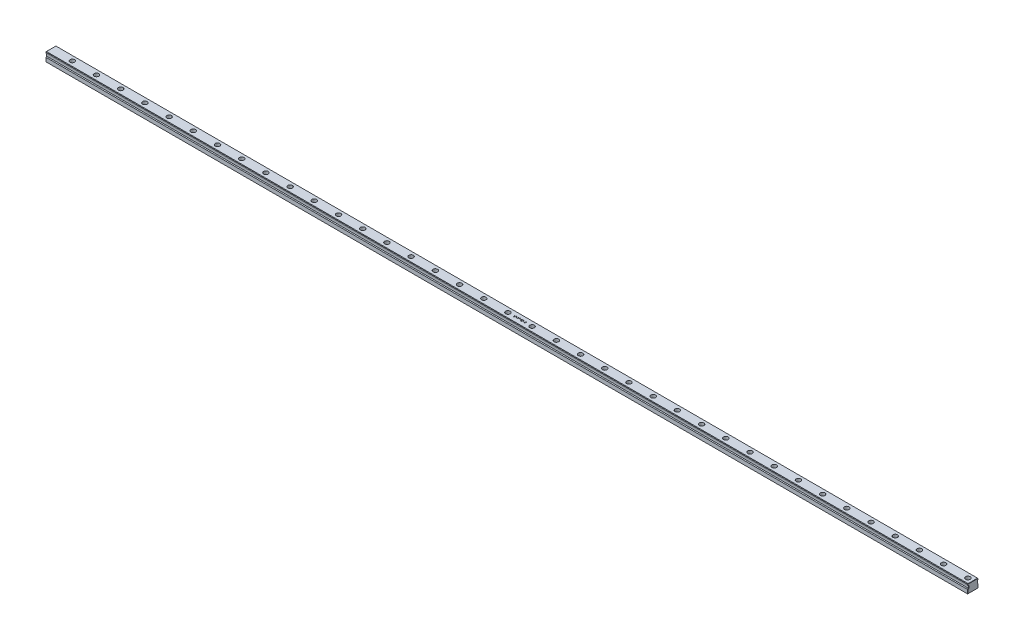
from build123d import *

# Parameters (mm, degrees)
BOSS_EXTRUDE1_DEPTH = 4000
SKETCH2_R           = 10
CUT_EXTRUDE1_DEPTH  = 17
SKETCH3_R           = 7
CUT_EXTRUDE2_DEPTH  = 22
LPATTERN1_COUNT     = 38
LPATTERN1_PITCH     = 105
CHAMFER1_SIZE       = 1
CUT_EXTRUDE3_DEPTH  = 2


with BuildPart() as part:
    # Sketch1 → Boss-Extrude1 (new body)
    with BuildSketch(Plane(origin=(0, 0, 0), x_dir=(0, 0, -1), z_dir=(1, 0, 0))):
        Polygon((-22.5, 0), (22.5, 0), (22.5, 17), (19.5, 20), (19.5, 29), (22.5, 32), (22.5, 36), (20.5, 38), (-20.5, 38), (-22.5, 36), (-22.5, 32), (-19.5, 29), (-19.5, 20), (-22.5, 17), align=None)
    extrude(amount=BOSS_EXTRUDE1_DEPTH)

    # Sketch2 → Cut-Extrude1 (cut)
    with BuildSketch(Plane(origin=(0, 38, 0), x_dir=(1, 0, 0), z_dir=(0, 1, 0))):
        with Locations(Location((3977.5, 0, 0), (0, 0, 270))):  # turned: the seam where the file's is
            Circle(SKETCH2_R)
    cut_extrude1 = extrude(amount=-CUT_EXTRUDE1_DEPTH, mode=Mode.SUBTRACT)

    # Sketch3 → Cut-Extrude2 (cut, through all)
    with BuildSketch(Plane(origin=(0, 21, 0), x_dir=(1, 0, 0), z_dir=(0, 1, 0))):
        with Locations(Location((3977.5, 0, 0), (0, 0, 270))):  # turned: the seam where the file's is
            Circle(SKETCH3_R)
    cut_extrude2 = extrude(amount=-CUT_EXTRUDE2_DEPTH, mode=Mode.SUBTRACT)

    # LPattern1: Cut-Extrude1, Cut-Extrude2 ×38
    with Locations(*[(-i * LPATTERN1_PITCH, 0, 0) for i in range(1, LPATTERN1_COUNT)]):
        add(cut_extrude1, mode=Mode.SUBTRACT)
        add(cut_extrude2, mode=Mode.SUBTRACT)

    # Chamfer1
    chamfer1_edges = [part.edges().sort_by_distance(p)[0] for p in [
        (4000, 8.5, -22.5),
        (0, 18.5, 21),
        (0, 24.5, 19.5),
        (4000, 18.5, -21),
        (0, 30.5, 21),
        (0, 34, 22.5),
        (0, 37, 21.5),
        (0, 38, 0),
        (0, 37, -21.5),
        (0, 34, -22.5),
        (0, 30.5, -21),
        (4000, 24.5, -19.5),
        (0, 24.5, -19.5),
        (0, 18.5, -21),
        (0, 8.5, -22.5),
        (0, 0, 0),
        (0, 8.5, 22.5),
        (4000, 30.5, -21),
        (4000, 34, -22.5),
        (4000, 37, -21.5),
        (4000, 38, 0),
        (4000, 37, 21.5),
        (4000, 34, 22.5),
        (4000, 30.5, 21),
        (4000, 8.5, 22.5),
        (4000, 24.5, 19.5),
        (4000, 18.5, 21),
        (4000, 0, 0),
    ]]
    chamfer(chamfer1_edges, length=CHAMFER1_SIZE)

    # Sketch5 → Cut-Extrude3 (cut)
    with BuildSketch(Plane(origin=(0, 38, 0), x_dir=(1, 0, 0), z_dir=(0, 1, 0))):
        with BuildLine():
            Line((2007.80688282, -1.573210853), (2008.589714518, -1.103882844))
            add(Edge.make_bspline(
                [(2008.589714518, -1.103882844), (2008.662523187, -1.22576153), (2008.802021788, -1.459276387), (2009.034726426, -1.774813286), (2009.27584892, -2.043000659), (2009.527174865, -2.262278349), (2009.787170186, -2.434916029), (2010.057532161, -2.557159434), (2010.337349702, -2.633401702), (2010.527780438, -2.642662348), (2010.622850869, -2.647285622)],
                knots=[0, 0, 0, 0, 1.272034388, 2.437168799, 3.508375237, 4.49857839, 5.41946034, 6.295179144, 7.148887113, 8, 8, 8, 8], degree=3))
            add(Edge.make_bspline(
                [(2010.622850869, -2.647285622), (2010.704043188, -2.645024301), (2010.86500715, -2.640541227), (2011.101973917, -2.597464938), (2011.332113269, -2.531287014), (2011.550681957, -2.436510799), (2011.754664103, -2.321844389), (2011.933540151, -2.183345128), (2012.088178826, -2.028282875), (2012.214673775, -1.855291268), (2012.311723035, -1.669243812), (2012.386314549, -1.478278274), (2012.427708807, -1.279394771), (2012.433944383, -1.145487921), (2012.437091154, -1.077912125)],
                knots=[0, 0, 0, 0, 1.095163259, 2.171163733, 3.241058638, 4.321873601, 5.38011039, 6.391990106, 7.366004449, 8.327778327, 9.272591725, 10.192022065, 11.087607919, 12, 12, 12, 12], degree=3))
            add(Edge.make_bspline(
                [(2012.437091154, -1.077912125), (2012.433190373, -1.000810293), (2012.425260657, -0.844073536), (2012.358237782, -0.612828621), (2012.252803317, -0.383983696), (2012.155535489, -0.242428265), (2012.10503695, -0.168936931)],
                knots=[0, 0, 0, 0, 0.938893495, 1.908633276, 2.914225137, 4, 4, 4, 4], degree=3))
            add(Edge.make_bspline(
                [(2012.10503695, -0.168936931), (2012.063575117, -0.115896377), (2011.976531184, -0.004544368), (2011.826889432, 0.161204484), (2011.651295754, 0.332174051), (2011.455759265, 0.514892806), (2011.233157135, 0.700862601), (2010.990461419, 0.898951587), (2010.721475792, 1.101626592), (2010.532829208, 1.237549839), (2010.435490676, 1.307683996)],
                knots=[0, 0, 0, 0, 0.722233717, 1.516239348, 2.393582979, 3.351407094, 4.387010283, 5.505090956, 6.712668013, 8, 8, 8, 8], degree=3))
            add(Edge.make_bspline(
                [(2010.435490676, 1.307683996), (2010.33806052, 1.377080467), (2010.151781479, 1.509761236), (2009.89127648, 1.706675488), (2009.658325505, 1.886708226), (2009.453963941, 2.051554258), (2009.278281674, 2.201235941), (2009.129894316, 2.334315905), (2009.012581883, 2.454393243), (2008.947347326, 2.532290127), (2008.918058618, 2.567263907)],
                knots=[0, 0, 0, 0, 1.452282411, 2.77665338, 3.964542531, 5.026858415, 5.96415736, 6.766646006, 7.446254459, 8, 8, 8, 8], degree=3))
            add(Edge.make_bspline(
                [(2008.918058618, 2.567263907), (2008.877120842, 2.621770817), (2008.796611212, 2.728965971), (2008.690338656, 2.89651299), (2008.600012121, 3.068024547), (2008.52920345, 3.243961522), (2008.469576371, 3.421853938), (2008.429471013, 3.604022859), (2008.404358359, 3.78965087), (2008.401786644, 3.914569924), (2008.400499273, 3.977102983)],
                knots=[0, 0, 0, 0, 1.068054152, 2.10047183, 3.106115577, 4.101338837, 5.06977816, 6.043150881, 7.020423561, 8, 8, 8, 8], degree=3))
            add(Edge.make_bspline(
                [(2008.400499273, 3.977102983), (2008.403952639, 4.075077595), (2008.410785556, 4.26893268), (2008.468571925, 4.552118419), (2008.559781456, 4.822486648), (2008.68756168, 5.077360656), (2008.85228426, 5.31010398), (2009.0429059, 5.523393831), (2009.269948791, 5.702698205), (2009.51906094, 5.859363443), (2009.791730924, 5.981987037), (2010.077456856, 6.074487963), (2010.376692859, 6.126899958), (2010.579371986, 6.13442144), (2010.682212514, 6.138237882)],
                knots=[0, 0, 0, 0, 1.005424448, 1.989358655, 2.955360095, 3.929531133, 4.905563448, 5.876582895, 6.856512386, 7.866279853, 8.892233794, 9.918561126, 10.94386622, 12, 12, 12, 12], degree=3))
            add(Edge.make_bspline(
                [(2010.682212514, 6.138237882), (2010.79133753, 6.134474048), (2011.008352356, 6.126988982), (2011.327570072, 6.061908014), (2011.634911968, 5.95422082), (2011.882147273, 5.832013329), (2012.075644371, 5.709957292), (2012.223209726, 5.59877984), (2012.372745481, 5.470787365), (2012.525457835, 5.325638943), (2012.678759163, 5.162002747), (2012.83492538, 4.980999466), (2012.994321675, 4.783735246), (2013.096863221, 4.642912087), (2013.149430897, 4.570719436)],
                knots=[0, 0, 0, 0, 1.286793592, 2.559021753, 3.825965368, 5.121522368, 5.803751409, 6.523245864, 7.299691795, 8.125521123, 9.008227632, 9.944561021, 10.946284179, 12, 12, 12, 12], degree=3))
            Line((2013.149430897, 4.570719436), (2012.398135074, 4.001218651))
            add(Edge.make_bspline(
                [(2012.398135074, 4.001218651), (2012.352769794, 4.059661645), (2012.265406872, 4.172209186), (2012.132772605, 4.329824958), (2012.007760557, 4.473801894), (2011.884595958, 4.598857545), (2011.769783641, 4.711840273), (2011.658348967, 4.808571296), (2011.551895579, 4.889998392), (2011.417707087, 4.976896978), (2011.249120624, 5.06303606), (2011.037494871, 5.135926329), (2010.816339519, 5.179728264), (2010.665713202, 5.185519696), (2010.589459944, 5.188451557)],
                knots=[0, 0, 0, 0, 1.181633172, 2.275549214, 3.290209073, 4.226197932, 5.078386478, 5.862611352, 6.581680152, 7.217281963, 8.414376989, 9.595101626, 10.782541182, 12, 12, 12, 12], degree=3))
            add(Edge.make_bspline(
                [(2010.589459944, 5.188451557), (2010.493795811, 5.185245601), (2010.309316544, 5.179063217), (2010.047404878, 5.111541589), (2009.811677201, 5.005227084), (2009.609131873, 4.856227037), (2009.440494454, 4.679694411), (2009.318507095, 4.476550357), (2009.245084784, 4.25223025), (2009.236125253, 4.095751284), (2009.231562307, 4.016059063)],
                knots=[0, 0, 0, 0, 1.14458467, 2.207223713, 3.21896685, 4.227309161, 5.202851033, 6.127160689, 7.046193047, 8, 8, 8, 8], degree=3))
            add(Edge.make_bspline(
                [(2009.231562307, 4.016059063), (2009.232602455, 3.966445776), (2009.234684451, 3.867138074), (2009.263721936, 3.720422854), (2009.301026411, 3.574078268), (2009.360141291, 3.428762268), (2009.441752823, 3.281933443), (2009.548922768, 3.131063429), (2009.683895489, 2.97482245), (2009.787286751, 2.87320294), (2009.841874223, 2.8195509)],
                knots=[0, 0, 0, 0, 0.858281714, 1.717966888, 2.583508476, 3.4729293, 4.427298488, 5.488583878, 6.674047936, 8, 8, 8, 8], degree=3))
            add(Edge.make_bspline(
                [(2009.841874223, 2.8195509), (2009.862144938, 2.801461269), (2009.910303515, 2.758484447), (2009.998346069, 2.688125704), (2010.114611389, 2.601335036), (2010.256063463, 2.493947761), (2010.425310441, 2.369378059), (2010.622370933, 2.22921871), (2010.845048322, 2.068919683), (2011.003062558, 1.956848691), (2011.086613723, 1.897590346)],
                knots=[0, 0, 0, 0, 0.420754252, 0.999615792, 1.744751191, 2.668019286, 3.750313428, 4.999500688, 6.413464383, 8, 8, 8, 8], degree=3))
            add(Edge.make_bspline(
                [(2011.086613723, 1.897590346), (2011.187118119, 1.824455916), (2011.381730951, 1.682841227), (2011.658637465, 1.47007474), (2011.909710665, 1.261985853), (2012.135832058, 1.059903434), (2012.339235545, 0.865360355), (2012.517664514, 0.676016107), (2012.672937043, 0.493227196), (2012.840098726, 0.258878922), (2013.010907956, -0.028937696), (2013.157596945, -0.381569703), (2013.250090906, -0.735572467), (2013.262186374, -0.973503889), (2013.268154188, -1.090897484)],
                knots=[0, 0, 0, 0, 1.163667725, 2.253281268, 3.268753668, 4.215851969, 5.092017293, 5.902905408, 6.650798638, 7.335211899, 8.59617414, 9.77448103, 10.901945474, 12, 12, 12, 12], degree=3))
            add(Edge.make_bspline(
                [(2013.268154188, -1.090897484), (2013.26641551, -1.173919409), (2013.262971918, -1.338351028), (2013.223387833, -1.579796752), (2013.165392053, -1.814299261), (2013.077981038, -2.038959913), (2012.971292682, -2.257888764), (2012.835915317, -2.465343001), (2012.678997068, -2.665914097), (2012.498991065, -2.854253751), (2012.302019615, -3.027148895), (2012.093835673, -3.180948703), (2011.874098493, -3.309187809), (2011.644000113, -3.413832745), (2011.403487681, -3.495677677), (2011.152642086, -3.554978393), (2010.891049838, -3.591373712), (2010.713248563, -3.595151331), (2010.622850869, -3.597071947)],
                knots=[0, 0, 0, 0, 0.983748083, 1.948392443, 2.894712957, 3.844097841, 4.80183111, 5.778335162, 6.776009319, 7.81870978, 8.863265674, 9.881300176, 10.883814829, 11.87499822, 12.874611388, 13.892143829, 14.928324115, 16, 16, 16, 16], degree=3))
            add(Edge.make_bspline(
                [(2010.622850869, -3.597071947), (2010.552907357, -3.595719446), (2010.413901201, -3.593031476), (2010.208294863, -3.569268505), (2010.0068422, -3.535647627), (2009.812071079, -3.4822704), (2009.621472094, -3.417508398), (2009.435874203, -3.337767393), (2009.255187456, -3.242207298), (2009.078399268, -3.132947545), (2008.905959264, -3.005794763), (2008.739484839, -2.85769822), (2008.573513869, -2.692742405), (2008.412945133, -2.506447789), (2008.254530772, -2.301824112), (2008.101394146, -2.076956897), (2007.950365435, -1.833070982), (2007.855603676, -1.661448776), (2007.80688282, -1.573210853)],
                knots=[0, 0, 0, 0, 0.915332311, 1.819136955, 2.706846663, 3.586547465, 4.459518054, 5.340707479, 6.227863349, 7.133153174, 8.059268498, 9.028702269, 10.047606654, 11.120612155, 12.245963614, 13.433783089, 14.680604001, 16, 16, 16, 16], degree=3))
        make_face()
        Polygon((2015.167726837, 5.900791301), (2015.998789871, 5.900791301), (2015.998789871, 2.101646002), (2020.747721495, 2.101646002), (2020.747721495, 5.900791301), (2021.57878453, 5.900791301), (2021.57878453, -3.359625366), (2020.747721495, -3.359625366), (2020.747721495, 1.151859677), (2015.998789871, 1.151859677), (2015.998789871, -3.359625366), (2015.167726837, -3.359625366), align=None)
        Polygon((2023.953250342, -3.359625366), (2023.953250342, 5.900791301), (2024.127625175, 5.900791301), (2030.245584743, -1.387705711), (2030.245584743, 5.900791301), (2031.076647777, 5.900791301), (2031.076647777, -3.359625366), (2030.887432533, -3.359625366), (2024.784313376, 3.912176183), (2024.784313376, -3.359625366), align=None)
        Polygon((2041.236764381, 6.138237882), (2041.40557406, 6.138237882), (2041.40557406, -0.27281981), (2042.474083675, -0.27281981), (2042.474083675, -1.222606135), (2041.40557406, -1.222606135), (2041.40557406, -3.359625366), (2040.574511025, -3.359625366), (2040.574511025, -1.222606135), (2036.181749273, -1.222606135), align=None)
        Polygon((2040.574511025, -0.27281981), (2040.574511025, 3.748931659), (2037.814194519, -0.27281981), align=None, mode=Mode.SUBTRACT)
        with BuildLine():
            Line((2049.122587948, 5.900791301), (2049.122587948, 4.951004976))
            Line((2049.122587948, 4.951004976), (2045.972710645, 4.951004976))
            Line((2045.972710645, 4.951004976), (2045.473701814, 2.515322467))
            add(Edge.make_bspline(
                [(2045.473701814, 2.515322467), (2045.571745482, 2.542390062), (2045.761689581, 2.594829244), (2046.042041713, 2.653052845), (2046.308191918, 2.688150999), (2046.480899669, 2.692943425), (2046.564472046, 2.695262455)],
                knots=[0, 0, 0, 0, 1.100273476, 2.13160584, 3.095893838, 4, 4, 4, 4], degree=3))
            add(Edge.make_bspline(
                [(2046.564472046, 2.695262455), (2046.667881108, 2.69302425), (2046.871209159, 2.68862338), (2047.168703873, 2.646364528), (2047.452688819, 2.579848504), (2047.722570091, 2.486925457), (2047.978846964, 2.368101788), (2048.219161554, 2.219670696), (2048.447121032, 2.046280424), (2048.658635812, 1.84693008), (2048.850523044, 1.627533302), (2049.019237225, 1.391636435), (2049.162542412, 1.141531995), (2049.277796909, 0.874830385), (2049.36983046, 0.594480125), (2049.43108678, 0.297531417), (2049.471876822, -0.013216734), (2049.476433969, -0.225689242), (2049.47875782, -0.334036507)],
                knots=[0, 0, 0, 0, 1.052922333, 2.070308379, 3.05430497, 4.020497103, 4.973039431, 5.925935799, 6.892292201, 7.88610001, 8.88166317, 9.857072816, 10.836096531, 11.812156883, 12.81219415, 13.836441305, 14.89672472, 16, 16, 16, 16], degree=3))
            add(Edge.make_bspline(
                [(2049.47875782, -0.334036507), (2049.476998142, -0.409501548), (2049.473502566, -0.559411786), (2049.455726303, -0.782043317), (2049.421500554, -0.999961646), (2049.37554845, -1.213195683), (2049.31590497, -1.42134173), (2049.243702681, -1.624995565), (2049.155342358, -1.822889628), (2049.058421845, -2.016896403), (2048.949290538, -2.202629953), (2048.828168238, -2.37632623), (2048.700201209, -2.540590891), (2048.562508376, -2.693662227), (2048.41380991, -2.834534378), (2048.255906664, -2.964043373), (2048.090058637, -3.084379393), (2047.913699975, -3.190657742), (2047.730760489, -3.288455564), (2047.538598331, -3.36868659), (2047.341587728, -3.440416529), (2047.136893161, -3.497591737), (2046.924978282, -3.542392454), (2046.705493772, -3.572821127), (2046.479590749, -3.594983784), (2046.326463111, -3.596371145), (2046.249113306, -3.597071947)],
                knots=[0, 0, 0, 0, 1.056347294, 2.098418968, 3.122841568, 4.141288669, 5.149314143, 6.15115421, 7.162517403, 8.180376062, 9.185164535, 10.17417709, 11.141909838, 12.097768115, 13.052685741, 14.0056014, 14.954263652, 15.917497458, 16.885230207, 17.854509472, 18.828990115, 19.81800267, 20.826176721, 21.857883937, 22.917946725, 24, 24, 24, 24], degree=3))
            add(Edge.make_bspline(
                [(2046.249113306, -3.597071947), (2046.156842036, -3.595244105), (2045.975309213, -3.591648041), (2045.709348546, -3.554028299), (2045.453457818, -3.50014877), (2045.209696926, -3.419090306), (2044.97588129, -3.317523922), (2044.755158683, -3.189158219), (2044.541889234, -3.043692673), (2044.344742803, -2.872030073), (2044.161767253, -2.684398997), (2043.997972948, -2.480781905), (2043.852098693, -2.264539423), (2043.726480488, -2.03462139), (2043.619329473, -1.791631944), (2043.535152316, -1.534660671), (2043.467211669, -1.265050244), (2043.438468869, -1.079435747), (2043.42387, -0.985159554)],
                knots=[0, 0, 0, 0, 1.0467383, 2.05933395, 3.04377827, 4.011590433, 4.970194871, 5.932262533, 6.905835911, 7.896367577, 8.894135286, 9.877477877, 10.858688626, 11.851381753, 12.8477658, 13.868841284, 14.917554742, 16, 16, 16, 16], degree=3))
            Line((2043.42387, -0.985159554), (2044.254933034, -0.985159554))
            add(Edge.make_bspline(
                [(2044.254933034, -0.985159554), (2044.275381509, -1.073468084), (2044.314684613, -1.243201983), (2044.400953989, -1.48167449), (2044.506432452, -1.69418577), (2044.631856457, -1.883546959), (2044.781478412, -2.048670764), (2044.952212527, -2.19582424), (2045.143632544, -2.32857927), (2045.356339631, -2.439235342), (2045.580740903, -2.533608918), (2045.815604146, -2.596451945), (2046.054534396, -2.640639724), (2046.216137584, -2.645062924), (2046.297344642, -2.647285622)],
                knots=[0, 0, 0, 0, 1.136247022, 2.183929868, 3.172523383, 4.106158343, 5.02341133, 5.958108904, 6.928429099, 7.938127109, 8.96079061, 9.975095812, 10.982467395, 12, 12, 12, 12], degree=3))
            add(Edge.make_bspline(
                [(2046.297344642, -2.647285622), (2046.376609693, -2.645113981), (2046.532683227, -2.640838001), (2046.762371688, -2.607926448), (2046.984126584, -2.557238707), (2047.195759799, -2.481383049), (2047.400974706, -2.389189732), (2047.594580306, -2.270881094), (2047.782177502, -2.134726461), (2047.957935272, -1.978737044), (2048.118906315, -1.806838061), (2048.261136052, -1.623012457), (2048.379608302, -1.426911634), (2048.479446465, -1.221930584), (2048.555258318, -1.005822735), (2048.609341748, -0.779600875), (2048.641099841, -0.54270624), (2048.645468588, -0.381127025), (2048.647694786, -0.29879053)],
                knots=[0, 0, 0, 0, 1.027316725, 2.022795036, 3.002884548, 3.971462791, 4.93288096, 5.914575861, 6.907176829, 7.935150275, 8.956128384, 9.956726525, 10.942570165, 11.921478529, 12.907843606, 13.90538589, 14.932640048, 16, 16, 16, 16], degree=3))
            add(Edge.make_bspline(
                [(2048.647694786, -0.29879053), (2048.645952559, -0.224506771), (2048.642542398, -0.079106881), (2048.614680264, 0.13361602), (2048.566216608, 0.334892611), (2048.498949259, 0.525694855), (2048.413543061, 0.706202713), (2048.309174693, 0.876602476), (2048.183885495, 1.034648243), (2048.040767373, 1.180413958), (2047.883980473, 1.314941023), (2047.710827237, 1.429622251), (2047.524931181, 1.5260997), (2047.328532032, 1.609358779), (2047.116958238, 1.669156585), (2046.894399648, 1.714050782), (2046.658452942, 1.740020595), (2046.497134663, 1.743623925), (2046.414212882, 1.74547613)],
                knots=[0, 0, 0, 0, 1.045622112, 2.046656509, 3.013763289, 3.955457236, 4.890082067, 5.820317437, 6.762574623, 7.722996705, 8.69280354, 9.665887285, 10.63943826, 11.638615906, 12.663482002, 13.728887084, 14.832589034, 16, 16, 16, 16], degree=3))
            add(Edge.make_bspline(
                [(2046.414212882, 1.74547613), (2046.342434257, 1.743939983), (2046.194229609, 1.740768228), (2045.96689213, 1.717414788), (2045.72799528, 1.679739988), (2045.478454843, 1.627918042), (2045.217521416, 1.560102485), (2044.945745647, 1.478837035), (2044.662556108, 1.381676747), (2044.471744629, 1.308301931), (2044.373656324, 1.270582968)],
                knots=[0, 0, 0, 0, 0.817624296, 1.688186739, 2.600797293, 3.572016777, 4.590301741, 5.671205678, 6.80286297, 8, 8, 8, 8], degree=3))
            Line((2044.373656324, 1.270582968), (2045.323442649, 5.900791301))
            Line((2045.323442649, 5.900791301), (2049.122587948, 5.900791301))
        make_face()
        with BuildLine():
            Line((2054.821305897, 5.900791301), (2056.628125976, 5.900791301))
            add(Edge.make_bspline(
                [(2056.628125976, 5.900791301), (2056.716572158, 5.900326295), (2056.888002871, 5.899424997), (2057.13729181, 5.885446712), (2057.370783455, 5.866387002), (2057.58854552, 5.836144882), (2057.790477378, 5.799654139), (2057.977187585, 5.755463917), (2058.148082416, 5.702476835), (2058.352109864, 5.618216882), (2058.584733279, 5.493007666), (2058.83661236, 5.307988338), (2059.05199441, 5.081683696), (2059.237695708, 4.82640667), (2059.38533617, 4.545589107), (2059.492146602, 4.24592417), (2059.559768481, 3.931277061), (2059.56672288, 3.71526282), (2059.570237521, 3.6060927)],
                knots=[0, 0, 0, 0, 1.001505555, 1.941167018, 2.826882275, 3.653841531, 4.429895133, 5.150066043, 5.825578002, 6.45369114, 7.647487171, 8.808567382, 9.977351308, 11.170798116, 12.373658725, 13.556498008, 14.765093433, 16, 16, 16, 16], degree=3))
            add(Edge.make_bspline(
                [(2059.570237521, 3.6060927), (2059.567345047, 3.50382448), (2059.561661063, 3.302857782), (2059.507308346, 3.008921285), (2059.422216577, 2.729121185), (2059.303933939, 2.464478624), (2059.150205741, 2.220973022), (2058.968018106, 1.996640048), (2058.748210733, 1.800977876), (2058.583525494, 1.691591446), (2058.499872854, 1.636028096)],
                knots=[0, 0, 0, 0, 1.044552857, 2.05264487, 3.044412934, 4.028983338, 5.005914585, 5.980388656, 6.974128949, 8, 8, 8, 8], degree=3))
            add(Edge.make_bspline(
                [(2058.499872854, 1.636028096), (2058.605072319, 1.595639453), (2058.806344955, 1.518365974), (2059.083326696, 1.381747142), (2059.321967223, 1.233151559), (2059.524101339, 1.070877705), (2059.696973884, 0.89596481), (2059.847926459, 0.705848154), (2059.976729261, 0.49804769), (2060.087094705, 0.274730003), (2060.173213288, 0.038175389), (2060.237707869, -0.20939729), (2060.274663411, -0.46710028), (2060.279922379, -0.642480346), (2060.282577265, -0.73101751)],
                knots=[0, 0, 0, 0, 1.27268992, 2.434971085, 3.483601985, 4.442670787, 5.356604649, 6.2567628, 7.179492994, 8.113709626, 9.066344395, 10.018646069, 10.999752585, 12, 12, 12, 12], degree=3))
            add(Edge.make_bspline(
                [(2060.282577265, -0.73101751), (2060.279992693, -0.821417359), (2060.274907475, -0.999281595), (2060.237389633, -1.260571222), (2060.173865538, -1.510271601), (2060.086364796, -1.749997814), (2059.972164506, -1.979286086), (2059.833184267, -2.198396181), (2059.667471588, -2.405126597), (2059.482096914, -2.601774516), (2059.272382487, -2.778589704), (2059.046122052, -2.936058344), (2058.800466164, -3.065561467), (2058.53944943, -3.174347607), (2058.260143844, -3.25744582), (2057.963803612, -3.315581588), (2057.650684313, -3.354753249), (2057.435816847, -3.35797377), (2057.325625308, -3.359625366)],
                knots=[0, 0, 0, 0, 0.978564426, 1.925352924, 2.850884081, 3.763762016, 4.682927383, 5.618979971, 6.567305752, 7.547517671, 8.540179244, 9.531824382, 10.526200242, 11.540722885, 12.589160233, 13.674978461, 14.80764778, 16, 16, 16, 16], degree=3))
            Line((2057.325625308, -3.359625366), (2054.821305897, -3.359625366))
            Line((2054.821305897, -3.359625366), (2054.821305897, 5.900791301))
        make_face()
        with BuildLine():
            Line((2055.652368931, 4.951004976), (2055.652368931, 1.982922711))
            Line((2055.652368931, 1.982922711), (2056.210739407, 1.982922711))
            add(Edge.make_bspline(
                [(2056.210739407, 1.982922711), (2056.292360178, 1.983980841), (2056.450068141, 1.986025363), (2056.678456201, 1.99188196), (2056.890453645, 2.00828095), (2057.085694537, 2.024675227), (2057.26387142, 2.051330907), (2057.424589553, 2.083060065), (2057.570371258, 2.116616918), (2057.738486305, 2.173686186), (2057.929179315, 2.258029201), (2058.132466903, 2.388923434), (2058.31168102, 2.544827452), (2058.463015246, 2.724720205), (2058.586870595, 2.922803655), (2058.672896467, 3.135917276), (2058.731229906, 3.358749709), (2058.736499166, 3.511727169), (2058.739174487, 3.589397237)],
                knots=[0, 0, 0, 0, 1.156816544, 2.235205308, 3.236616184, 4.169592532, 5.011045266, 5.787822928, 6.49130361, 7.128639758, 8.301311294, 9.436451833, 10.541879658, 11.654887649, 12.756523258, 13.837046038, 14.901820046, 16, 16, 16, 16], degree=3))
            add(Edge.make_bspline(
                [(2058.739174487, 3.589397237), (2058.737782302, 3.640794591), (2058.735051379, 3.741616113), (2058.712685349, 3.888590446), (2058.674671142, 4.026818708), (2058.625844157, 4.158195208), (2058.557611585, 4.278611978), (2058.477274922, 4.392232517), (2058.3802107, 4.495187497), (2058.26972781, 4.591415128), (2058.142704995, 4.676728774), (2057.999218036, 4.751449127), (2057.83732564, 4.811617432), (2057.659756211, 4.864312252), (2057.463776459, 4.901322946), (2057.251647953, 4.932155868), (2057.021633176, 4.947852914), (2056.862499258, 4.949930853), (2056.780240192, 4.951004976)],
                knots=[0, 0, 0, 0, 0.91205012, 1.789085906, 2.630437955, 3.453916878, 4.269457761, 5.079663411, 5.91843418, 6.774407191, 7.675494373, 8.627863946, 9.638891023, 10.736472738, 11.911756761, 13.175263542, 14.539845004, 16, 16, 16, 16], degree=3))
            Line((2056.780240192, 4.951004976), (2055.652368931, 4.951004976))
        make_face(mode=Mode.SUBTRACT)
        with BuildLine():
            Line((2055.652368931, 1.033136386), (2055.652368931, -2.409839041))
            Line((2055.652368931, -2.409839041), (2056.835891734, -2.409839041))
            add(Edge.make_bspline(
                [(2056.835891734, -2.409839041), (2056.920608476, -2.408823709), (2057.083888827, -2.406866791), (2057.319635831, -2.400478282), (2057.53813696, -2.385946636), (2057.738395153, -2.363071159), (2057.922572809, -2.338257346), (2058.088460481, -2.304889998), (2058.237402889, -2.266660457), (2058.410107828, -2.207567959), (2058.60458586, -2.11576688), (2058.814164585, -1.977352156), (2059.00050062, -1.812455071), (2059.158735368, -1.621608694), (2059.288415567, -1.414092475), (2059.382753959, -1.194103736), (2059.440938101, -0.965277445), (2059.447981757, -0.809261351), (2059.45151423, -0.73101751)],
                knots=[0, 0, 0, 0, 1.160039823, 2.235823828, 3.228722157, 4.157150951, 4.99529583, 5.772374946, 6.472645482, 7.099169577, 8.269452708, 9.405989375, 10.527446681, 11.663510218, 12.788923519, 13.866172445, 14.929861265, 16, 16, 16, 16], degree=3))
            add(Edge.make_bspline(
                [(2059.45151423, -0.73101751), (2059.450783704, -0.682087213), (2059.449334436, -0.58501587), (2059.427478225, -0.442363598), (2059.395691528, -0.304182642), (2059.354597943, -0.170097786), (2059.294750603, -0.042533228), (2059.224883286, 0.081033961), (2059.142964577, 0.200767125), (2059.015318555, 0.352141212), (2058.829655179, 0.526546642), (2058.565847669, 0.697302117), (2058.265883464, 0.83501194), (2058.048323223, 0.893483471), (2057.935937224, 0.923688353)],
                knots=[0, 0, 0, 0, 0.723448775, 1.435228256, 2.130040452, 2.821711965, 3.505591119, 4.210454504, 4.921174351, 5.648778258, 7.137944449, 8.670945889, 10.280296675, 12, 12, 12, 12], degree=3))
            add(Edge.make_bspline(
                [(2057.935937224, 0.923688353), (2057.890881074, 0.932829929), (2057.793190049, 0.952650752), (2057.633890826, 0.973573217), (2057.452027173, 0.992213272), (2057.247179143, 1.006001126), (2057.019087564, 1.020253023), (2056.7672653, 1.02579557), (2056.492740738, 1.032408196), (2056.302260919, 1.032887447), (2056.203319202, 1.033136386)],
                knots=[0, 0, 0, 0, 0.634451884, 1.375622551, 2.216452059, 3.157844607, 4.20941857, 5.370758133, 6.634282058, 8, 8, 8, 8], degree=3))
            Line((2056.203319202, 1.033136386), (2055.652368931, 1.033136386))
        make_face(mode=Mode.SUBTRACT)
    extrude(amount=-CUT_EXTRUDE3_DEPTH, mode=Mode.SUBTRACT)


solid = part.part
